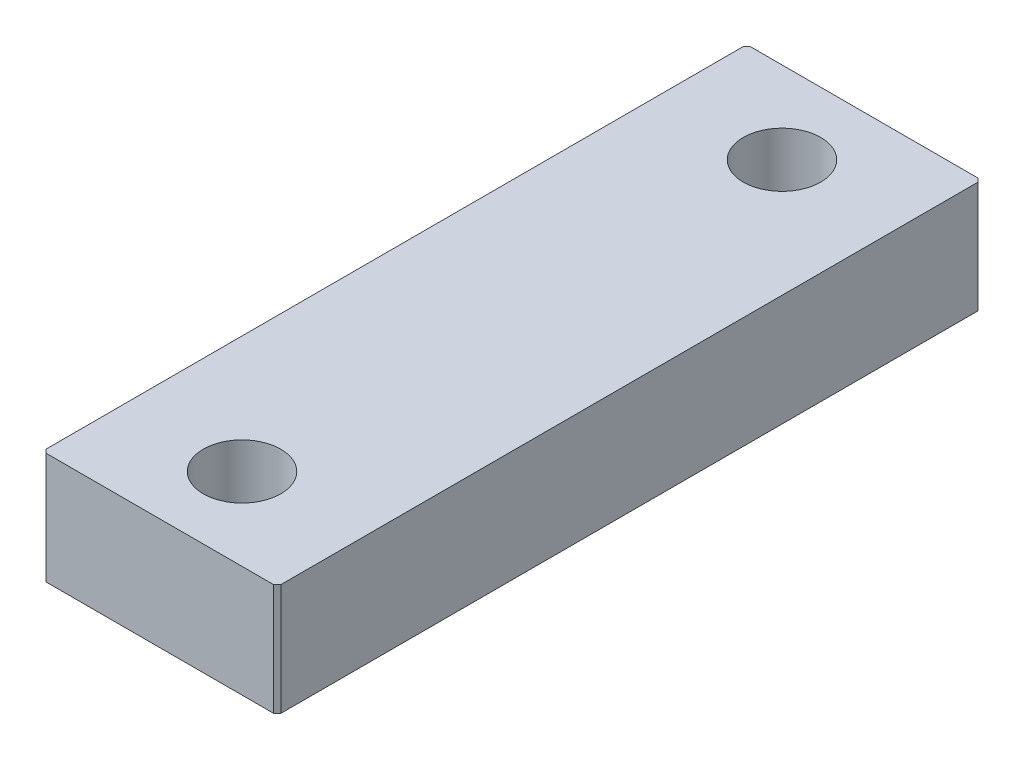
from build123d import *

# Parameters (mm, degrees)
SKETCH1_W           = 20
SKETCH1_H           = 60
SKETCH1_R           = 3.3
BOSS_EXTRUDE1_DEPTH = 9.5
CHAMFER1_SIZE       = 0.3


with BuildPart() as part:
    # Sketch1 → Boss-Extrude1 (new body)
    with BuildSketch(Plane(origin=(0, 0, 0), x_dir=(1, 0, 0), z_dir=(0, 1, 0))):
        Rectangle(SKETCH1_W, SKETCH1_H)
        with Locations((0, 23)):
            Circle(SKETCH1_R, mode=Mode.SUBTRACT)
        with Locations((0, -23)):
            Circle(SKETCH1_R, mode=Mode.SUBTRACT)
    extrude(amount=BOSS_EXTRUDE1_DEPTH)

    # Chamfer1
    chamfer1_edges = [part.edges().sort_by_distance(p)[0] for p in [
        (-10, 4.75, -30),
        (10, 4.75, -30),
        (10, 4.75, 30),
        (-10, 4.75, 30),
    ]]
    chamfer(chamfer1_edges, length=CHAMFER1_SIZE)


solid = part.part
